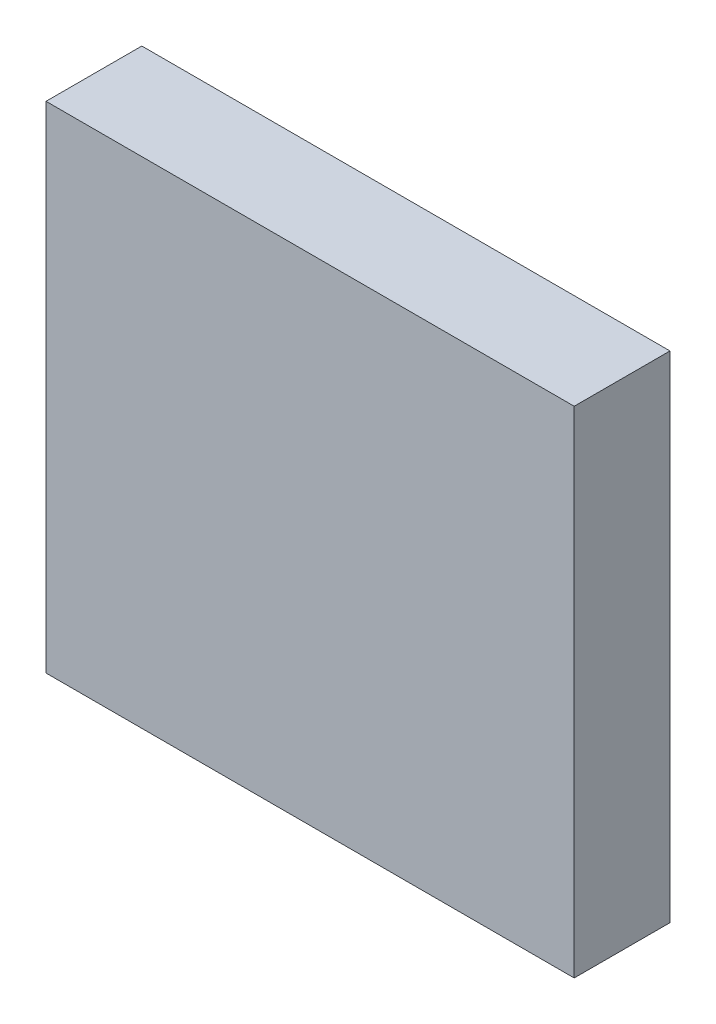
from build123d import *

# Parameters (mm, degrees)
SKETCH1_W           = 90
SKETCH1_H           = 96
BOSS_EXTRUDE1_DEPTH = 17.41


with BuildPart() as part:
    # Sketch1 → Boss-Extrude1 (new body)
    with BuildSketch(Plane(origin=(0, 0, 0), x_dir=(0, 1, 0), z_dir=(0, 0, 1))):
        with Locations((45, 48)):
            Rectangle(SKETCH1_W, SKETCH1_H)
    extrude(amount=BOSS_EXTRUDE1_DEPTH)


solid = part.part
